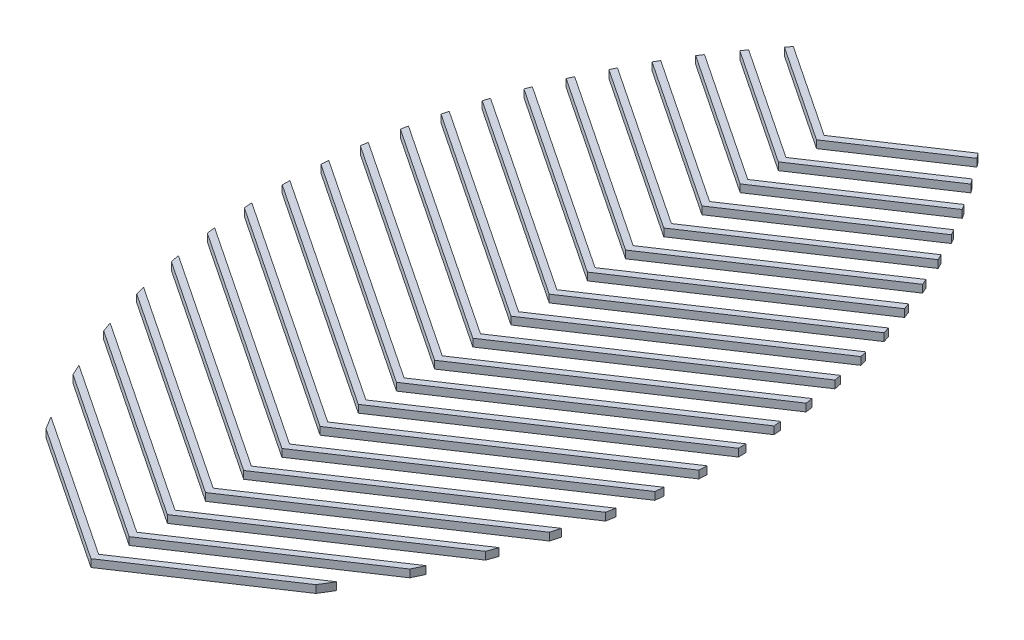
from build123d import *

# Parameters (mm, degrees)
BOSS_EXTRUDE1_DEPTH    = 1.27
BOSS_EXTRUDE1_2_DEPTH  = 1.27
BOSS_EXTRUDE1_3_DEPTH  = 1.27
BOSS_EXTRUDE1_4_DEPTH  = 1.27
BOSS_EXTRUDE1_5_DEPTH  = 1.27
BOSS_EXTRUDE1_6_DEPTH  = 1.27
BOSS_EXTRUDE1_7_DEPTH  = 1.27
BOSS_EXTRUDE1_8_DEPTH  = 1.27
BOSS_EXTRUDE1_9_DEPTH  = 1.27
BOSS_EXTRUDE1_10_DEPTH = 1.27
BOSS_EXTRUDE1_11_DEPTH = 1.27
BOSS_EXTRUDE1_12_DEPTH = 1.27
BOSS_EXTRUDE1_13_DEPTH = 1.27
BOSS_EXTRUDE1_14_DEPTH = 1.27
BOSS_EXTRUDE1_15_DEPTH = 1.27
BOSS_EXTRUDE1_16_DEPTH = 1.27
BOSS_EXTRUDE1_17_DEPTH = 1.27
BOSS_EXTRUDE1_18_DEPTH = 1.27
BOSS_EXTRUDE1_19_DEPTH = 1.27
BOSS_EXTRUDE1_20_DEPTH = 1.27
SCALE1_SCALE           = 1.5


with BuildPart() as part:
    # Sketch2 → Boss-Extrude1 (new body)
    with BuildSketch(Plane(origin=(0, 0, 0), x_dir=(1, 0, 0), z_dir=(0, 1, 0))):
        with BuildLine():
            Line((-15.087606914, 6.892180812), (8.663604478, -8.941960116))
            Line((8.663604478, -8.941960116), (32.414815871, 6.892180812))
            ThreePointArc((32.414815871, 6.892180812), (31.763310765, 5.814245807), (31.098367122, 4.744548313))
            Line((31.098367122, 4.744548313), (8.663604478, -10.211960116))
            Line((8.663604478, -10.211960116), (-13.771158165, 4.744548313))
            ThreePointArc((-13.771158165, 4.744548313), (-14.436101809, 5.814245807), (-15.087606914, 6.892180812))
        make_face()
    extrude(amount=BOSS_EXTRUDE1_DEPTH)


with BuildPart() as body_2:
    # Sketch2 → Boss-Extrude1 2 (new body)
    with BuildSketch(Plane(origin=(0, 0, 0), x_dir=(1, 0, 0), z_dir=(0, 1, 0))):
        with BuildLine():
            Line((-20.200842721, 16.651004683), (8.663604478, -2.591960116))
            Line((8.663604478, -2.591960116), (37.528051677, 16.651004683))
            ThreePointArc((37.528051677, 16.651004683), (37.100323041, 15.72554455), (36.663241676, 14.804464682))
            Line((36.663241676, 14.804464682), (8.663604478, -3.861960116))
            Line((8.663604478, -3.861960116), (-19.33603272, 14.804464682))
            ThreePointArc((-19.33603272, 14.804464682), (-19.773114085, 15.72554455), (-20.200842721, 16.651004683))
        make_face()
    extrude(amount=BOSS_EXTRUDE1_2_DEPTH)


with BuildPart() as body_3:
    # Sketch2 → Boss-Extrude1 3 (new body)
    with BuildSketch(Plane(origin=(0, 0, 0), x_dir=(1, 0, 0), z_dir=(0, 1, 0))):
        with BuildLine():
            Line((-23.677538133, 25.318801624), (8.663604478, 3.758039884))
            Line((8.663604478, 3.758039884), (41.00474709, 25.318801624))
            ThreePointArc((41.00474709, 25.318801624), (40.709743564, 24.483370348), (40.407397183, 23.650568353))
            Line((40.407397183, 23.650568353), (8.663604478, 2.488039884))
            Line((8.663604478, 2.488039884), (-23.080188226, 23.650568353))
            ThreePointArc((-23.080188226, 23.650568353), (-23.382534608, 24.483370348), (-23.677538133, 25.318801624))
        make_face()
    extrude(amount=BOSS_EXTRUDE1_3_DEPTH)


with BuildPart() as body_4:
    # Sketch2 → Boss-Extrude1 4 (new body)
    with BuildSketch(Plane(origin=(0, 0, 0), x_dir=(1, 0, 0), z_dir=(0, 1, 0))):
        with BuildLine():
            Line((-26.083660644, 33.272883298), (8.663604478, 10.108039884))
            Line((8.663604478, 10.108039884), (43.4108696, 33.272883298))
            ThreePointArc((43.4108696, 33.272883298), (43.208198171, 32.499908642), (42.999395914, 31.728567508))
            Line((42.999395914, 31.728567508), (8.663604478, 8.838039884))
            Line((8.663604478, 8.838039884), (-25.672186958, 31.728567508))
            ThreePointArc((-25.672186958, 31.728567508), (-25.880989214, 32.499908642), (-26.083660644, 33.272883298))
        make_face()
    extrude(amount=BOSS_EXTRUDE1_4_DEPTH)


with BuildPart() as body_5:
    # Sketch2 → Boss-Extrude1 5 (new body)
    with BuildSketch(Plane(origin=(0, 0, 0), x_dir=(1, 0, 0), z_dir=(0, 1, 0))):
        with BuildLine():
            Line((-27.703585423, 40.702833151), (8.663604478, 16.458039884))
            Line((8.663604478, 16.458039884), (45.030794379, 40.702833151))
            ThreePointArc((45.030794379, 40.702833151), (44.898357724, 39.977275913), (44.760607656, 39.252708669))
            Line((44.760607656, 39.252708669), (8.663604478, 15.188039884))
            Line((8.663604478, 15.188039884), (-27.433398699, 39.252708669))
            ThreePointArc((-27.433398699, 39.252708669), (-27.571148767, 39.977275913), (-27.703585423, 40.702833151))
        make_face()
    extrude(amount=BOSS_EXTRUDE1_5_DEPTH)


with BuildPart() as body_6:
    # Sketch2 → Boss-Extrude1 6 (new body)
    with BuildSketch(Plane(origin=(0, 0, 0), x_dir=(1, 0, 0), z_dir=(0, 1, 0))):
        with BuildLine():
            Line((-28.704328317, 47.71999508), (8.663604478, 22.808039884))
            Line((8.663604478, 22.808039884), (46.031537273, 47.71999508))
            ThreePointArc((46.031537273, 47.71999508), (45.955705368, 47.032597992), (45.875151945, 46.345738195))
            Line((45.875151945, 46.345738195), (8.663604478, 21.538039884))
            Line((8.663604478, 21.538039884), (-28.547942988, 46.345738195))
            ThreePointArc((-28.547942988, 46.345738195), (-28.628496412, 47.032597992), (-28.704328317, 47.71999508))
        make_face()
    extrude(amount=BOSS_EXTRUDE1_6_DEPTH)


with BuildPart() as body_7:
    # Sketch2 → Boss-Extrude1 7 (new body)
    with BuildSketch(Plane(origin=(0, 0, 0), x_dir=(1, 0, 0), z_dir=(0, 1, 0))):
        with BuildLine():
            Line((-29.193738592, 54.396268597), (8.663604478, 29.158039884))
            Line((8.663604478, 29.158039884), (46.520947548, 54.396268597))
            ThreePointArc((46.520947548, 54.396268597), (46.492635423, 53.740870856), (46.460052016, 53.085671576))
            Line((46.460052016, 53.085671576), (8.663604478, 27.888039884))
            Line((8.663604478, 27.888039884), (-29.13284306, 53.085671576))
            ThreePointArc((-29.13284306, 53.085671576), (-29.165426466, 53.740870856), (-29.193738592, 54.396268597))
        make_face()
    extrude(amount=BOSS_EXTRUDE1_7_DEPTH)


with BuildPart() as body_8:
    # Sketch2 → Boss-Extrude1 8 (new body)
    with BuildSketch(Plane(origin=(0, 0, 0), x_dir=(1, 0, 0), z_dir=(0, 1, 0))):
        with BuildLine():
            Line((-29.246009729, 60.781116022), (8.663604478, 35.508039884))
            Line((8.663604478, 35.508039884), (46.573218686, 60.781116022))
            ThreePointArc((46.573218686, 60.781116022), (46.586038756, 60.153391226), (46.594942657, 59.52559867))
            Line((46.594942657, 59.52559867), (8.663604478, 34.238039884))
            Line((8.663604478, 34.238039884), (-29.267733701, 59.52559867))
            ThreePointArc((-29.267733701, 59.52559867), (-29.2588298, 60.153391226), (-29.246009729, 60.781116022))
        make_face()
    extrude(amount=BOSS_EXTRUDE1_8_DEPTH)


with BuildPart() as body_9:
    # Sketch2 → Boss-Extrude1 9 (new body)
    with BuildSketch(Plane(origin=(0, 0, 0), x_dir=(1, 0, 0), z_dir=(0, 1, 0))):
        with BuildLine():
            Line((-28.914494067, 66.910105581), (8.663604478, 41.858039884))
            Line((8.663604478, 41.858039884), (46.241703024, 66.910105581))
            ThreePointArc((46.241703024, 66.910105581), (46.290990718, 66.306897384), (46.336650215, 65.703403708))
            Line((46.336650215, 65.703403708), (8.663604478, 40.588039884))
            Line((8.663604478, 40.588039884), (-29.009441259, 65.703403708))
            ThreePointArc((-29.009441259, 65.703403708), (-28.963781762, 66.306897384), (-28.914494067, 66.910105581))
        make_face()
    extrude(amount=BOSS_EXTRUDE1_9_DEPTH)


with BuildPart() as body_10:
    # Sketch2 → Boss-Extrude1 10 (new body)
    with BuildSketch(Plane(origin=(0, 0, 0), x_dir=(1, 0, 0), z_dir=(0, 1, 0))):
        with BuildLine():
            Line((-28.238784609, 72.809632608), (8.663604478, 48.208039884))
            Line((8.663604478, 48.208039884), (45.565993565, 72.809632608))
            ThreePointArc((45.565993565, 72.809632608), (45.648249628, 72.228575035), (45.727116225, 71.647047715))
            Line((45.727116225, 71.647047715), (8.663604478, 46.938039884))
            Line((8.663604478, 46.938039884), (-28.399907268, 71.647047715))
            ThreePointArc((-28.399907268, 71.647047715), (-28.321040671, 72.228575035), (-28.238784609, 72.809632608))
        make_face()
    extrude(amount=BOSS_EXTRUDE1_10_DEPTH)


with BuildPart() as body_11:
    # Sketch2 → Boss-Extrude1 11 (new body)
    with BuildSketch(Plane(origin=(0, 0, 0), x_dir=(1, 0, 0), z_dir=(0, 1, 0))):
        with BuildLine():
            Line((-27.248914654, 78.499719305), (8.663604478, 54.558039884))
            Line((8.663604478, 54.558039884), (44.576123611, 78.499719305))
            ThreePointArc((44.576123611, 78.499719305), (44.688674576, 77.939005878), (44.798037586, 77.377661955))
            Line((44.798037586, 77.377661955), (8.663604478, 53.288039884))
            Line((8.663604478, 53.288039884), (-27.470828629, 77.377661955))
            ThreePointArc((-27.470828629, 77.377661955), (-27.361465619, 77.939005878), (-27.248914654, 78.499719305))
        make_face()
    extrude(amount=BOSS_EXTRUDE1_11_DEPTH)


with BuildPart() as body_12:
    # Sketch2 → Boss-Extrude1 12 (new body)
    with BuildSketch(Plane(origin=(0, 0, 0), x_dir=(1, 0, 0), z_dir=(0, 1, 0))):
        with BuildLine():
            Line((-25.967985314, 83.995766412), (8.663604478, 60.908039884))
            Line((8.663604478, 60.908039884), (43.295194271, 83.995766412))
            ThreePointArc((43.295194271, 83.995766412), (43.435975759, 83.454002944), (43.573741969, 82.911464877))
            Line((43.573741969, 82.911464877), (8.663604478, 59.638039884))
            Line((8.663604478, 59.638039884), (-26.246533012, 82.911464877))
            ThreePointArc((-26.246533012, 82.911464877), (-26.108766803, 83.454002944), (-25.967985314, 83.995766412))
        make_face()
    extrude(amount=BOSS_EXTRUDE1_12_DEPTH)


with BuildPart() as body_13:
    # Sketch2 → Boss-Extrude1 13 (new body)
    with BuildSketch(Plane(origin=(0, 0, 0), x_dir=(1, 0, 0), z_dir=(0, 1, 0))):
        with BuildLine():
            Line((-24.413878016, 89.30969488), (8.663604478, 67.258039884))
            Line((8.663604478, 67.258039884), (41.741086973, 89.30969488))
            ThreePointArc((41.741086973, 89.30969488), (41.908500323, 88.785802168), (42.07304829, 88.261002425))
            Line((42.07304829, 88.261002425), (8.663604478, 65.988039884))
            Line((8.663604478, 65.988039884), (-24.745839334, 88.261002425))
            ThreePointArc((-24.745839334, 88.261002425), (-24.581291366, 88.785802168), (-24.413878016, 89.30969488))
        make_face()
    extrude(amount=BOSS_EXTRUDE1_13_DEPTH)


with BuildPart() as body_14:
    # Sketch2 → Boss-Extrude1 14 (new body)
    with BuildSketch(Plane(origin=(0, 0, 0), x_dir=(1, 0, 0), z_dir=(0, 1, 0))):
        with BuildLine():
            Line((-22.600404845, 94.450712766), (8.663604478, 73.608039884))
            Line((8.663604478, 73.608039884), (39.927613802, 94.450712766))
            ThreePointArc((39.927613802, 94.450712766), (40.120428758, 93.943860588), (40.310509946, 93.435976862))
            Line((40.310509946, 93.435976862), (8.663604478, 72.338039884))
            Line((8.663604478, 72.338039884), (-22.983300989, 93.435976862))
            ThreePointArc((-22.983300989, 93.435976862), (-22.793219802, 93.943860588), (-22.600404845, 94.450712766))
        make_face()
    extrude(amount=BOSS_EXTRUDE1_14_DEPTH)


with BuildPart() as body_15:
    # Sketch2 → Boss-Extrude1 15 (new body)
    with BuildSketch(Plane(origin=(0, 0, 0), x_dir=(1, 0, 0), z_dir=(0, 1, 0))):
        with BuildLine():
            Line((-20.538096709, 99.425840676), (8.663604478, 79.958039884))
            Line((8.663604478, 79.958039884), (37.865305666, 99.425840676))
            ThreePointArc((37.865305666, 99.425840676), (38.082593335, 98.935402349), (38.297263996, 98.443812896))
            Line((38.297263996, 98.443812896), (8.663604478, 78.688039884))
            Line((8.663604478, 78.688039884), (-20.97005504, 98.443812896))
            ThreePointArc((-20.97005504, 98.443812896), (-20.755384379, 98.935402349), (-20.538096709, 99.425840676))
        make_face()
    extrude(amount=BOSS_EXTRUDE1_15_DEPTH)


with BuildPart() as body_16:
    # Sketch2 → Boss-Extrude1 16 (new body)
    with BuildSketch(Plane(origin=(0, 0, 0), x_dir=(1, 0, 0), z_dir=(0, 1, 0))):
        with BuildLine():
            Line((-18.23474744, 104.240274496), (8.663604478, 86.308039884))
            Line((8.663604478, 86.308039884), (35.561956397, 104.240274496))
            ThreePointArc((35.561956397, 104.240274496), (35.80304301, 103.765795549), (36.041617201, 103.290048366))
            Line((36.041617201, 103.290048366), (8.663604478, 85.038039884))
            Line((8.663604478, 85.038039884), (-18.714408244, 103.290048366))
            ThreePointArc((-18.714408244, 103.290048366), (-18.475834053, 103.765795549), (-18.23474744, 104.240274496))
        make_face()
    extrude(amount=BOSS_EXTRUDE1_16_DEPTH)


with BuildPart() as body_17:
    # Sketch2 → Boss-Extrude1 17 (new body)
    with BuildSketch(Plane(origin=(0, 0, 0), x_dir=(1, 0, 0), z_dir=(0, 1, 0))):
        with BuildLine():
            Line((-15.695785688, 108.897633328), (8.663604478, 92.658039884))
            Line((8.663604478, 92.658039884), (33.022994645, 108.897633328))
            ThreePointArc((33.022994645, 108.897633328), (33.287430312, 108.438810337), (33.549448114, 107.978602307))
            Line((33.549448114, 107.978602307), (8.663604478, 91.388039884))
            Line((8.663604478, 91.388039884), (-16.222239157, 107.978602307))
            ThreePointArc((-16.222239157, 107.978602307), (-15.960221355, 108.438810337), (-15.695785688, 108.897633328))
        make_face()
    extrude(amount=BOSS_EXTRUDE1_17_DEPTH)


with BuildPart() as body_18:
    # Sketch2 → Boss-Extrude1 18 (new body)
    with BuildSketch(Plane(origin=(0, 0, 0), x_dir=(1, 0, 0), z_dir=(0, 1, 0))):
        with BuildLine():
            Line((-12.9245188, 113.400122069), (8.663604478, 99.008039884))
            Line((8.663604478, 99.008039884), (30.251727756, 113.400122069))
            ThreePointArc((30.251727756, 113.400122069), (30.539266651, 112.956789246), (30.824473971, 112.511952879))
            Line((30.824473971, 112.511952879), (8.663604478, 97.738039884))
            Line((8.663604478, 97.738039884), (-13.497265014, 112.511952879))
            ThreePointArc((-13.497265014, 112.511952879), (-13.212057694, 112.956789246), (-12.9245188, 113.400122069))
        make_face()
    extrude(amount=BOSS_EXTRUDE1_18_DEPTH)


with BuildPart() as body_19:
    # Sketch2 → Boss-Extrude1 19 (new body)
    with BuildSketch(Plane(origin=(0, 0, 0), x_dir=(1, 0, 0), z_dir=(0, 1, 0))):
        with BuildLine():
            Line((-9.922275394, 117.748626466), (8.663604478, 105.358039884))
            Line((8.663604478, 105.358039884), (27.249484351, 117.748626466))
            ThreePointArc((27.249484351, 117.748626466), (27.560074213, 117.320748546), (27.86841202, 116.891244912))
            Line((27.86841202, 116.891244912), (8.663604478, 104.088039884))
            Line((8.663604478, 104.088039884), (-10.541203064, 116.891244912))
            ThreePointArc((-10.541203064, 116.891244912), (-10.232865256, 117.320748546), (-9.922275394, 117.748626466))
        make_face()
    extrude(amount=BOSS_EXTRUDE1_19_DEPTH)


with BuildPart() as body_20:
    # Sketch2 → Boss-Extrude1 20 (new body)
    with BuildSketch(Plane(origin=(0, 0, 0), x_dir=(1, 0, 0), z_dir=(0, 1, 0))):
        with BuildLine():
            Line((-6.688461368, 121.942750448), (8.663604478, 111.708039884))
            Line((8.663604478, 111.708039884), (24.015670325, 121.942750448))
            ThreePointArc((24.015670325, 121.942750448), (24.349450219, 121.53042118), (24.681052123, 121.116338314))
            Line((24.681052123, 121.116338314), (8.663604478, 110.438039884))
            Line((8.663604478, 110.438039884), (-7.353843166, 121.116338314))
            ThreePointArc((-7.353843166, 121.116338314), (-7.022241262, 121.53042118), (-6.688461368, 121.942750448))
        make_face()
    extrude(amount=BOSS_EXTRUDE1_20_DEPTH)


with BuildPart() as body_20_1:
    # Scale1: scaled about (0, 0, 0)
    add(body_20.part.scale(SCALE1_SCALE))


with BuildPart() as body_10_1:
    # Scale1: scaled about (0, 0, 0)
    add(body_10.part.scale(SCALE1_SCALE))


with BuildPart() as body_9_1:
    # Scale1: scaled about (0, 0, 0)
    add(body_9.part.scale(SCALE1_SCALE))


with BuildPart() as body_8_1:
    # Scale1: scaled about (0, 0, 0)
    add(body_8.part.scale(SCALE1_SCALE))


with BuildPart() as body_7_1:
    # Scale1: scaled about (0, 0, 0)
    add(body_7.part.scale(SCALE1_SCALE))


with BuildPart() as body_6_1:
    # Scale1: scaled about (0, 0, 0)
    add(body_6.part.scale(SCALE1_SCALE))


with BuildPart() as body_5_1:
    # Scale1: scaled about (0, 0, 0)
    add(body_5.part.scale(SCALE1_SCALE))


with BuildPart() as body_14_1:
    # Scale1: scaled about (0, 0, 0)
    add(body_14.part.scale(SCALE1_SCALE))


with BuildPart() as body_12_1:
    # Scale1: scaled about (0, 0, 0)
    add(body_12.part.scale(SCALE1_SCALE))


with BuildPart() as body_18_1:
    # Scale1: scaled about (0, 0, 0)
    add(body_18.part.scale(SCALE1_SCALE))


with BuildPart() as body_4_1:
    # Scale1: scaled about (0, 0, 0)
    add(body_4.part.scale(SCALE1_SCALE))


with BuildPart() as body_15_1:
    # Scale1: scaled about (0, 0, 0)
    add(body_15.part.scale(SCALE1_SCALE))


with BuildPart() as part_1:
    # Scale1: scaled about (0, 0, 0)
    add(part.part.scale(SCALE1_SCALE))


with BuildPart() as body_19_1:
    # Scale1: scaled about (0, 0, 0)
    add(body_19.part.scale(SCALE1_SCALE))


with BuildPart() as body_13_1:
    # Scale1: scaled about (0, 0, 0)
    add(body_13.part.scale(SCALE1_SCALE))


with BuildPart() as body_16_1:
    # Scale1: scaled about (0, 0, 0)
    add(body_16.part.scale(SCALE1_SCALE))


with BuildPart() as body_2_1:
    # Scale1: scaled about (0, 0, 0)
    add(body_2.part.scale(SCALE1_SCALE))


with BuildPart() as body_17_1:
    # Scale1: scaled about (0, 0, 0)
    add(body_17.part.scale(SCALE1_SCALE))


with BuildPart() as body_11_1:
    # Scale1: scaled about (0, 0, 0)
    add(body_11.part.scale(SCALE1_SCALE))


with BuildPart() as body_3_1:
    # Scale1: scaled about (0, 0, 0)
    add(body_3.part.scale(SCALE1_SCALE))


solid = Compound([body_20_1.part, body_10_1.part, body_9_1.part, body_8_1.part, body_7_1.part, body_6_1.part, body_5_1.part, body_14_1.part, body_12_1.part, body_18_1.part, body_4_1.part, body_15_1.part, part_1.part, body_19_1.part, body_13_1.part, body_16_1.part, body_2_1.part, body_17_1.part, body_11_1.part, body_3_1.part])
